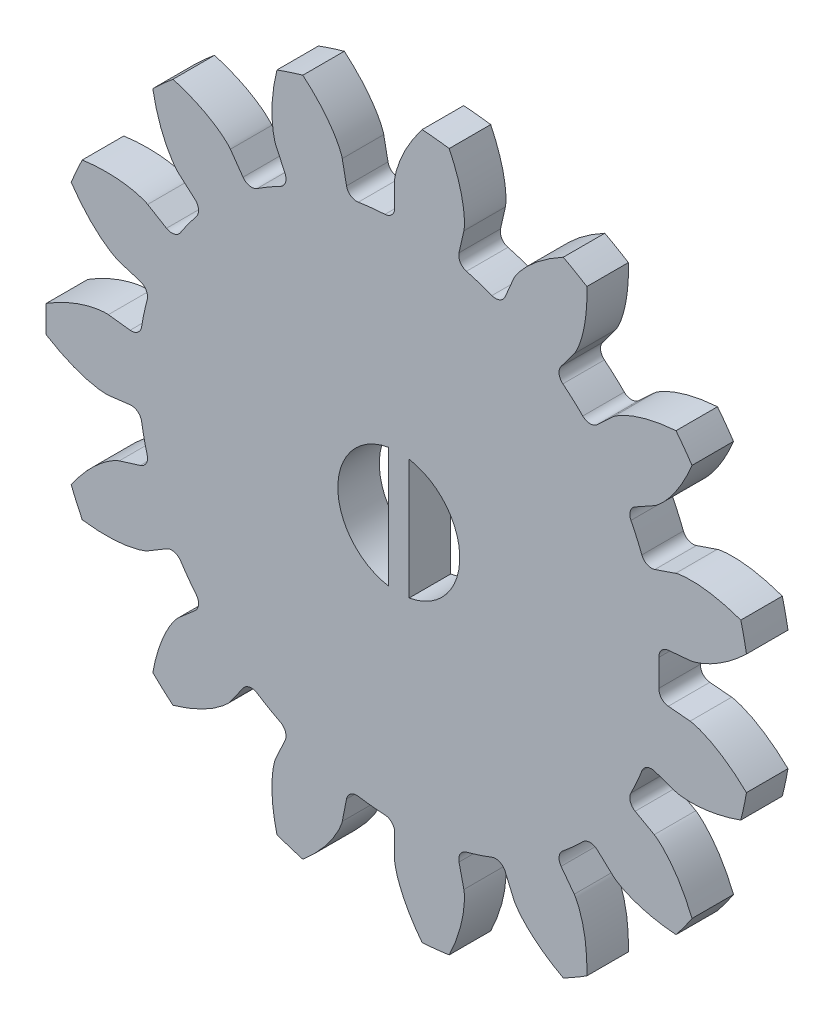
from build123d import *

# Parameters (mm, degrees)
BOSS_EXTRUDE1_DEPTH = 2


with BuildPart() as part:
    # Model → Boss-Extrude1 (new body)
    with BuildSketch(Plane.XY):
        with BuildLine():
            Line((-54.481196543, -102.831203323), (-54.924387915, -103.789903349))
            add(Edge.make_bspline(
                [(-54.924387915, -103.789903349), (-54.938844158, -103.821174719), (-54.95455115, -103.861076701), (-54.977503798, -103.934729714), (-54.997679447, -104.018619757), (-55.025551936, -104.136716214), (-55.044914627, -104.230522739), (-55.064352418, -104.351618793), (-55.078032946, -104.456434474), (-55.091533867, -104.579585969), (-55.103699645, -104.721366375), (-55.112590945, -104.900478214), (-55.116296533, -105.081064783), (-55.113044886, -105.299764415), (-55.100518203, -105.547871597), (-55.079947553, -105.78858276), (-55.051387133, -106.030757954), (-55.013189585, -106.283605293), (-54.970568466, -106.518677571), (-54.93325868, -106.697892255), (-54.903174984, -106.830156052), (-54.882766309, -106.915275478), (-54.873484818, -106.953124336)],
                knots=[0, 0, 0, 0, 0, 0, 0.057142857, 0.071428571, 0.128571429, 0.142857143, 0.2, 0.214285714, 0.271428571, 0.3, 0.342857143, 0.428571429, 0.5, 0.557142857, 0.642857143, 0.728571429, 0.8, 0.871428571, 0.942857143, 1, 1, 1, 1, 1, 1], degree=5))
            ThreePointArc((-54.873484818, -106.953124336), (-54.253288904, -107.167960777), (-53.625262179, -107.358696457))
            add(Edge.make_bspline(
                [(-51.724786063, -104.829517011), (-51.731471566, -104.863313247), (-51.74221814, -104.904826967), (-51.766941212, -104.977904734), (-51.799928099, -105.057632154), (-51.846794138, -105.169557232), (-51.886267484, -105.256829409), (-51.941720454, -105.366223422), (-51.992261787, -105.459062302), (-52.053725945, -105.566629597), (-52.127220056, -105.688483219), (-52.22530614, -105.838613916), (-52.328454378, -105.986889609), (-52.459633434, -106.161910058), (-52.615601476, -106.355269985), (-52.773729953, -106.537918282), (-52.939182826, -106.717054736), (-53.118705228, -106.899160575), (-53.291358456, -107.064285978), (-53.426882456, -107.18734356), (-53.528963386, -107.276664467), (-53.595506294, -107.333531611), (-53.625262179, -107.358696457)],
                knots=[0, 0, 0, 0, 0, 0, 0.057142857, 0.071428571, 0.128571429, 0.142857143, 0.2, 0.214285714, 0.271428571, 0.3, 0.342857143, 0.428571429, 0.5, 0.557142857, 0.642857143, 0.728571429, 0.8, 0.871428571, 0.942857143, 1, 1, 1, 1, 1, 1], degree=5))
            Line((-51.724786063, -104.829517011), (-51.519825677, -103.793411045))
            ThreePointArc((-51.519825677, -103.793411045), (-51.315631569, -103.480523025), (-50.951573701, -103.396522929))
            ThreePointArc((-50.951573701, -103.396522929), (-50.311748591, -103.480454169), (-49.668454909, -103.531384148))
            ThreePointArc((-49.668454909, -103.531384148), (-49.329817181, -103.689240527), (-49.195138281, -104.037745536))
            Line((-49.195138281, -104.037745536), (-49.210075315, -105.093823761))
            add(Edge.make_bspline(
                [(-49.210075315, -105.093823761), (-49.210562539, -105.128271463), (-49.208681991, -105.171112346), (-49.1996929, -105.247733405), (-49.184003118, -105.332576949), (-49.161431747, -105.451800193), (-49.140965894, -105.545372233), (-49.109468998, -105.663905045), (-49.079334403, -105.765223307), (-49.041577883, -105.883219116), (-48.995024587, -106.017690228), (-48.930295846, -106.184933453), (-48.860229895, -106.351414691), (-48.768306213, -106.549884183), (-48.655948236, -106.771446311), (-48.539249962, -106.982980063), (-48.414657195, -107.192601542), (-48.276919721, -107.408052738), (-48.142370881, -107.605466379), (-48.035393517, -107.754011882), (-47.95411416, -107.862604731), (-47.900848719, -107.932064241), (-47.876975137, -107.962865771)],
                knots=[0, 0, 0, 0, 0, 0, 0.057142857, 0.071428571, 0.128571429, 0.142857143, 0.2, 0.214285714, 0.271428571, 0.3, 0.342857143, 0.428571429, 0.5, 0.557142857, 0.642857143, 0.728571429, 0.8, 0.871428571, 0.942857143, 1, 1, 1, 1, 1, 1], degree=5))
            ThreePointArc((-47.876975137, -107.962865771), (-47.223016124, -107.906872221), (-46.571705972, -107.825676453))
            add(Edge.make_bspline(
                [(-45.864244606, -104.742162783), (-45.85660595, -104.77575642), (-45.849538282, -104.818052116), (-45.842400526, -104.894867757), (-45.840107485, -104.981119355), (-45.837397711, -105.102430137), (-45.837961614, -105.198212494), (-45.84412587, -105.320703653), (-45.852536701, -105.426073202), (-45.864935442, -105.549340541), (-45.88251332, -105.690552112), (-45.911055762, -105.867598533), (-45.944977208, -106.045009287), (-45.99362801, -106.258253752), (-46.057465338, -106.498334753), (-46.127633135, -106.729508921), (-46.205920495, -106.960453961), (-46.295853253, -107.199834261), (-46.386417273, -107.420908218), (-46.460172579, -107.58844949), (-46.517098063, -107.711568253), (-46.554758083, -107.790584414), (-46.571705972, -107.825676453)],
                knots=[0, 0, 0, 0, 0, 0, 0.057142857, 0.071428571, 0.128571429, 0.142857143, 0.2, 0.214285714, 0.271428571, 0.3, 0.342857143, 0.428571429, 0.5, 0.557142857, 0.642857143, 0.728571429, 0.8, 0.871428571, 0.942857143, 1, 1, 1, 1, 1, 1], degree=5))
            Line((-45.864244606, -104.742162783), (-46.098426239, -103.712267985))
            ThreePointArc((-46.098426239, -103.712267985), (-46.039148662, -103.343377329), (-45.740731168, -103.118563748))
            ThreePointArc((-45.740731168, -103.118563748), (-45.122083934, -102.934998434), (-44.513690824, -102.719874173))
            ThreePointArc((-44.513690824, -102.719874173), (-44.140123892, -102.726346778), (-43.875338838, -102.989943102))
            Line((-43.875338838, -102.989943102), (-43.459438785, -103.960794006))
            add(Edge.make_bspline(
                [(-43.459438785, -103.960794006), (-43.445872744, -103.992461719), (-43.426729821, -104.030833926), (-43.387353285, -104.097174553), (-43.338510978, -104.168301378), (-43.269398542, -104.268036627), (-43.212642878, -104.345194728), (-43.135657393, -104.440668898), (-43.066918222, -104.520970892), (-42.984432705, -104.613408467), (-42.887209824, -104.71731901), (-42.760053229, -104.843775747), (-42.628330778, -104.967365536), (-42.463629501, -105.111287709), (-42.270867945, -105.267994678), (-42.078220238, -105.413774913), (-41.879138345, -105.554597219), (-41.665677005, -105.695398802), (-41.462465163, -105.821019194), (-41.304317578, -105.913210649), (-41.1858965, -105.979355861), (-41.10898437, -106.021145273), (-41.074646657, -106.039573611)],
                knots=[0, 0, 0, 0, 0, 0, 0.057142857, 0.071428571, 0.128571429, 0.142857143, 0.2, 0.214285714, 0.271428571, 0.3, 0.342857143, 0.428571429, 0.5, 0.557142857, 0.642857143, 0.728571429, 0.8, 0.871428571, 0.942857143, 1, 1, 1, 1, 1, 1], degree=5))
            ThreePointArc((-41.074646657, -106.039573611), (-40.5, -105.722431864), (-39.938023863, -105.383344134))
            add(Edge.make_bspline(
                [(-40.545903745, -102.278663766), (-40.525261721, -102.306246159), (-40.501601877, -102.34201052), (-40.463837476, -102.409281914), (-40.426660993, -102.487144006), (-40.374843951, -102.596864755), (-40.336400908, -102.684595653), (-40.292210594, -102.799004123), (-40.257036613, -102.898684989), (-40.218226083, -103.016338329), (-40.176848354, -103.152491085), (-40.130911904, -103.325840295), (-40.089741233, -103.501710179), (-40.047451614, -103.716306755), (-40.008120175, -103.961596644), (-39.978194642, -104.201324569), (-39.955779894, -104.444145699), (-39.940572816, -104.699409434), (-39.933388287, -104.938206248), (-39.932621937, -105.121261802), (-39.934549042, -105.256890069), (-39.936814414, -105.344392634), (-39.938023863, -105.383344134)],
                knots=[0, 0, 0, 0, 0, 0, 0.057142857, 0.071428571, 0.128571429, 0.142857143, 0.2, 0.214285714, 0.271428571, 0.3, 0.342857143, 0.428571429, 0.5, 0.557142857, 0.642857143, 0.728571429, 0.8, 0.871428571, 0.942857143, 1, 1, 1, 1, 1, 1], degree=5))
            Line((-40.545903745, -102.278663766), (-41.178735265, -101.433058303))
            ThreePointArc((-41.178735265, -101.433058303), (-41.274623851, -101.071949557), (-41.093445825, -100.745194802))
            ThreePointArc((-41.093445825, -100.745194802), (-40.602946195, -100.325873044), (-40.134650353, -99.881891481))
            ThreePointArc((-40.134650353, -99.881891481), (-39.790747333, -99.73586114), (-39.441639865, -99.86897058))
            Line((-39.441639865, -99.86897058), (-38.666815624, -100.586725223))
            add(Edge.make_bspline(
                [(-38.666815624, -100.586725223), (-38.641542009, -100.610137312), (-38.608446696, -100.637405939), (-38.545491277, -100.681995238), (-38.471941722, -100.727106869), (-38.368238391, -100.790108993), (-38.285006484, -100.837511817), (-38.175843901, -100.893418994), (-38.08038578, -100.938819776), (-37.967433762, -100.98971582), (-37.836352015, -101.045098716), (-37.668754097, -101.108903448), (-37.498151153, -101.16823199), (-37.289150629, -101.232721393), (-37.049315719, -101.297477145), (-36.814029118, -101.352297135), (-36.574881167, -101.399970812), (-36.322605366, -101.44177691), (-36.085867694, -101.473883145), (-35.903895043, -101.493779813), (-35.768808324, -101.506040279), (-35.681548311, -101.512933825), (-35.64268377, -101.515802543)],
                knots=[0, 0, 0, 0, 0, 0, 0.057142857, 0.071428571, 0.128571429, 0.142857143, 0.2, 0.214285714, 0.271428571, 0.3, 0.342857143, 0.428571429, 0.5, 0.557142857, 0.642857143, 0.728571429, 0.8, 0.871428571, 0.942857143, 1, 1, 1, 1, 1, 1], degree=5))
            ThreePointArc((-35.64268377, -101.515802543), (-35.246711096, -100.992349289), (-34.871239753, -100.454000946))
            add(Edge.make_bspline(
                [(-36.689352929, -97.864981321), (-36.659276732, -97.881783223), (-36.623115713, -97.904832267), (-36.561254475, -97.950927578), (-36.495622702, -98.0069371), (-36.40365803, -98.086096103), (-36.332855192, -98.150606071), (-36.245951213, -98.237149589), (-36.173274322, -98.313906045), (-36.089965214, -98.405602055), (-35.996786462, -98.513153948), (-35.884313952, -98.652832294), (-35.775169946, -98.796751807), (-35.649252166, -98.975594797), (-35.513552722, -99.183680723), (-35.388708256, -99.390511269), (-35.269467114, -99.60322251), (-35.151749642, -99.83023226), (-35.048058833, -100.045461793), (-34.972903337, -100.21237966), (-34.919498849, -100.337066072), (-34.88597787, -100.417925053), (-34.871239753, -100.454000946)],
                knots=[0, 0, 0, 0, 0, 0, 0.057142857, 0.071428571, 0.128571429, 0.142857143, 0.2, 0.214285714, 0.271428571, 0.3, 0.342857143, 0.428571429, 0.5, 0.557142857, 0.642857143, 0.728571429, 0.8, 0.871428571, 0.942857143, 1, 1, 1, 1, 1, 1], degree=5))
            Line((-36.689352929, -97.864981321), (-37.611412017, -97.349878059))
            ThreePointArc((-37.611412017, -97.349878059), (-37.845886758, -97.058990206), (-37.813275528, -96.686793142))
            ThreePointArc((-37.813275528, -96.686793142), (-37.535735343, -96.104219481), (-37.288509374, -95.508149062))
            ThreePointArc((-37.288509374, -95.508149062), (-37.033734224, -95.234865748), (-36.660668195, -95.214472473))
            Line((-36.660668195, -95.214472473), (-35.660893915, -95.555024555))
            add(Edge.make_bspline(
                [(-35.660893915, -95.555024555), (-35.628282764, -95.566132858), (-35.586957542, -95.577582912), (-35.511308803, -95.592710987), (-35.425769388, -95.604007214), (-35.305406408, -95.619382573), (-35.210089813, -95.628833742), (-35.087625333, -95.635507067), (-34.981953838, -95.638156429), (-34.858065749, -95.638710554), (-34.715790362, -95.635989598), (-34.536730322, -95.626109906), (-34.356745686, -95.610918758), (-34.139584003, -95.584824587), (-33.894145373, -95.546432264), (-33.656903069, -95.500813134), (-33.419039913, -95.44709497), (-33.17157043, -95.382676929), (-32.942241022, -95.315717549), (-32.767908029, -95.259879114), (-32.63951339, -95.216134888), (-32.556993544, -95.186940612), (-32.520322206, -95.173753683)],
                knots=[0, 0, 0, 0, 0, 0, 0.057142857, 0.071428571, 0.128571429, 0.142857143, 0.2, 0.214285714, 0.271428571, 0.3, 0.342857143, 0.428571429, 0.5, 0.557142857, 0.642857143, 0.728571429, 0.8, 0.871428571, 0.942857143, 1, 1, 1, 1, 1, 1], degree=5))
            ThreePointArc((-32.520322206, -95.173753683), (-32.371490788, -94.534498744), (-32.247446646, -93.889975107))
            add(Edge.make_bspline(
                [(-34.96142483, -92.264281239), (-34.927114908, -92.267397449), (-34.884705282, -92.273745787), (-34.809443578, -92.290694716), (-34.726704844, -92.315167114), (-34.610494069, -92.350077059), (-34.51957389, -92.380211739), (-34.404982735, -92.423926145), (-34.307369428, -92.464486301), (-34.193966644, -92.514369908), (-34.065098322, -92.574724238), (-33.90553727, -92.656580066), (-33.747291919, -92.743664216), (-33.559518306, -92.855830042), (-33.350914525, -92.990732059), (-33.152737867, -93.128902345), (-32.957288207, -93.274723992), (-32.757414763, -93.434227708), (-32.575146757, -93.588674819), (-32.438597181, -93.710593384), (-32.339095222, -93.802778527), (-32.275583973, -93.863012671), (-32.247446646, -93.889975107)],
                knots=[0, 0, 0, 0, 0, 0, 0.057142857, 0.071428571, 0.128571429, 0.142857143, 0.2, 0.214285714, 0.271428571, 0.3, 0.342857143, 0.428571429, 0.5, 0.557142857, 0.642857143, 0.728571429, 0.8, 0.871428571, 0.942857143, 1, 1, 1, 1, 1, 1], degree=5))
            Line((-34.96142483, -92.264281239), (-36.013279093, -92.168746212))
            ThreePointArc((-36.013279093, -92.168746212), (-36.345797177, -91.998376404), (-36.467391521, -91.645093284))
            ThreePointArc((-36.467391521, -91.645093284), (-36.4508, -91), (-36.467391521, -90.354906716))
            ThreePointArc((-36.467391521, -90.354906716), (-36.345797177, -90.001623596), (-36.013279093, -89.831253788))
            Line((-36.013279093, -89.831253788), (-34.96142483, -89.735718761))
            add(Edge.make_bspline(
                [(-34.96142483, -89.735718761), (-34.927114908, -89.732602551), (-34.884705282, -89.726254213), (-34.809443578, -89.709305284), (-34.726704844, -89.684832886), (-34.610494069, -89.649922941), (-34.51957389, -89.619788261), (-34.404982735, -89.576073855), (-34.307369428, -89.535513699), (-34.193966644, -89.485630092), (-34.065098322, -89.425275762), (-33.90553727, -89.343419934), (-33.747291919, -89.256335784), (-33.559518306, -89.144169958), (-33.350914525, -89.009267941), (-33.152737867, -88.871097655), (-32.957288207, -88.725276008), (-32.757414763, -88.565772292), (-32.575146757, -88.411325181), (-32.438597181, -88.289406616), (-32.339095222, -88.197221473), (-32.275583973, -88.136987329), (-32.247446646, -88.110024893)],
                knots=[0, 0, 0, 0, 0, 0, 0.057142857, 0.071428571, 0.128571429, 0.142857143, 0.2, 0.214285714, 0.271428571, 0.3, 0.342857143, 0.428571429, 0.5, 0.557142857, 0.642857143, 0.728571429, 0.8, 0.871428571, 0.942857143, 1, 1, 1, 1, 1, 1], degree=5))
            ThreePointArc((-32.247446646, -88.110024893), (-32.371490788, -87.465501256), (-32.520322206, -86.826246317))
            add(Edge.make_bspline(
                [(-35.660893915, -86.444975445), (-35.628282764, -86.433867142), (-35.586957542, -86.422417088), (-35.511308803, -86.407289013), (-35.425769388, -86.395992786), (-35.305406408, -86.380617427), (-35.210089813, -86.371166258), (-35.087625333, -86.364492933), (-34.981953838, -86.361843571), (-34.858065749, -86.361289446), (-34.715790362, -86.364010402), (-34.536730322, -86.373890094), (-34.356745686, -86.389081242), (-34.139584003, -86.415175413), (-33.894145373, -86.453567736), (-33.656903069, -86.499186866), (-33.419039913, -86.55290503), (-33.17157043, -86.617323071), (-32.942241022, -86.684282451), (-32.767908029, -86.740120886), (-32.63951339, -86.783865112), (-32.556993544, -86.813059388), (-32.520322206, -86.826246317)],
                knots=[0, 0, 0, 0, 0, 0, 0.057142857, 0.071428571, 0.128571429, 0.142857143, 0.2, 0.214285714, 0.271428571, 0.3, 0.342857143, 0.428571429, 0.5, 0.557142857, 0.642857143, 0.728571429, 0.8, 0.871428571, 0.942857143, 1, 1, 1, 1, 1, 1], degree=5))
            Line((-35.660893915, -86.444975445), (-36.660668195, -86.785527527))
            ThreePointArc((-36.660668195, -86.785527527), (-37.033734224, -86.765134252), (-37.288509374, -86.491850938))
            ThreePointArc((-37.288509374, -86.491850938), (-37.535735343, -85.895780519), (-37.813275528, -85.313206858))
            ThreePointArc((-37.813275528, -85.313206858), (-37.845886758, -84.941009794), (-37.611412017, -84.650121941))
            Line((-37.611412017, -84.650121941), (-36.689352929, -84.135018679))
            add(Edge.make_bspline(
                [(-36.689352929, -84.135018679), (-36.659276732, -84.118216777), (-36.623115713, -84.095167733), (-36.561254475, -84.049072422), (-36.495622702, -83.9930629), (-36.40365803, -83.913903897), (-36.332855192, -83.849393929), (-36.245951213, -83.762850411), (-36.173274322, -83.686093955), (-36.089965214, -83.594397945), (-35.996786462, -83.486846052), (-35.884313952, -83.347167706), (-35.775169946, -83.203248193), (-35.649252166, -83.024405203), (-35.513552722, -82.816319277), (-35.388708256, -82.609488731), (-35.269467114, -82.39677749), (-35.151749642, -82.16976774), (-35.048058833, -81.954538207), (-34.972903337, -81.78762034), (-34.919498849, -81.662933928), (-34.88597787, -81.582074947), (-34.871239753, -81.545999054)],
                knots=[0, 0, 0, 0, 0, 0, 0.057142857, 0.071428571, 0.128571429, 0.142857143, 0.2, 0.214285714, 0.271428571, 0.3, 0.342857143, 0.428571429, 0.5, 0.557142857, 0.642857143, 0.728571429, 0.8, 0.871428571, 0.942857143, 1, 1, 1, 1, 1, 1], degree=5))
            ThreePointArc((-34.871239753, -81.545999054), (-35.246711096, -81.007650711), (-35.64268377, -80.484197457))
            add(Edge.make_bspline(
                [(-38.666815624, -81.413274777), (-38.641542009, -81.389862688), (-38.608446696, -81.362594061), (-38.545491277, -81.318004762), (-38.471941722, -81.272893131), (-38.368238391, -81.209891007), (-38.285006484, -81.162488183), (-38.175843901, -81.106581006), (-38.08038578, -81.061180224), (-37.967433762, -81.01028418), (-37.836352015, -80.954901284), (-37.668754097, -80.891096552), (-37.498151153, -80.83176801), (-37.289150629, -80.767278607), (-37.049315719, -80.702522855), (-36.814029118, -80.647702865), (-36.574881167, -80.600029188), (-36.322605366, -80.55822309), (-36.085867694, -80.526116855), (-35.903895043, -80.506220187), (-35.768808324, -80.493959721), (-35.681548311, -80.487066175), (-35.64268377, -80.484197457)],
                knots=[0, 0, 0, 0, 0, 0, 0.057142857, 0.071428571, 0.128571429, 0.142857143, 0.2, 0.214285714, 0.271428571, 0.3, 0.342857143, 0.428571429, 0.5, 0.557142857, 0.642857143, 0.728571429, 0.8, 0.871428571, 0.942857143, 1, 1, 1, 1, 1, 1], degree=5))
            Line((-38.666815624, -81.413274777), (-39.441639865, -82.13102942))
            ThreePointArc((-39.441639865, -82.13102942), (-39.790747333, -82.26413886), (-40.134650353, -82.118108519))
            ThreePointArc((-40.134650353, -82.118108519), (-40.602946195, -81.674126956), (-41.093445825, -81.254805198))
            ThreePointArc((-41.093445825, -81.254805198), (-41.274623851, -80.928050443), (-41.178735265, -80.566941697))
            Line((-41.178735265, -80.566941697), (-40.545903745, -79.721336234))
            add(Edge.make_bspline(
                [(-40.545903745, -79.721336234), (-40.525261721, -79.693753841), (-40.501601877, -79.65798948), (-40.463837476, -79.590718086), (-40.426660993, -79.512855994), (-40.374843951, -79.403135245), (-40.336400908, -79.315404347), (-40.292210594, -79.200995877), (-40.257036613, -79.101315011), (-40.218226083, -78.983661671), (-40.176848354, -78.847508915), (-40.130911904, -78.674159705), (-40.089741233, -78.498289821), (-40.047451614, -78.283693245), (-40.008120175, -78.038403356), (-39.978194642, -77.798675431), (-39.955779894, -77.555854301), (-39.940572816, -77.300590566), (-39.933388287, -77.061793752), (-39.932621937, -76.878738198), (-39.934549042, -76.743109931), (-39.936814414, -76.655607366), (-39.938023863, -76.616655866)],
                knots=[0, 0, 0, 0, 0, 0, 0.057142857, 0.071428571, 0.128571429, 0.142857143, 0.2, 0.214285714, 0.271428571, 0.3, 0.342857143, 0.428571429, 0.5, 0.557142857, 0.642857143, 0.728571429, 0.8, 0.871428571, 0.942857143, 1, 1, 1, 1, 1, 1], degree=5))
            ThreePointArc((-39.938023863, -76.616655866), (-40.5, -76.277568136), (-41.074646657, -75.960426389))
            add(Edge.make_bspline(
                [(-43.459438785, -78.039205994), (-43.445872744, -78.007538281), (-43.426729821, -77.969166074), (-43.387353285, -77.902825447), (-43.338510978, -77.831698622), (-43.269398542, -77.731963373), (-43.212642878, -77.654805272), (-43.135657393, -77.559331102), (-43.066918222, -77.479029108), (-42.984432705, -77.386591533), (-42.887209824, -77.28268099), (-42.760053229, -77.156224253), (-42.628330778, -77.032634464), (-42.463629501, -76.888712291), (-42.270867945, -76.732005322), (-42.078220238, -76.586225087), (-41.879138345, -76.445402781), (-41.665677005, -76.304601198), (-41.462465163, -76.178980806), (-41.304317578, -76.086789351), (-41.1858965, -76.020644139), (-41.10898437, -75.978854727), (-41.074646657, -75.960426389)],
                knots=[0, 0, 0, 0, 0, 0, 0.057142857, 0.071428571, 0.128571429, 0.142857143, 0.2, 0.214285714, 0.271428571, 0.3, 0.342857143, 0.428571429, 0.5, 0.557142857, 0.642857143, 0.728571429, 0.8, 0.871428571, 0.942857143, 1, 1, 1, 1, 1, 1], degree=5))
            Line((-43.459438785, -78.039205994), (-43.875338838, -79.010056898))
            ThreePointArc((-43.875338838, -79.010056898), (-44.140123892, -79.273653222), (-44.513690824, -79.280125827))
            ThreePointArc((-44.513690824, -79.280125827), (-45.122083934, -79.065001566), (-45.740731168, -78.881436252))
            ThreePointArc((-45.740731168, -78.881436252), (-46.039148662, -78.656622671), (-46.098426239, -78.287732015))
            Line((-46.098426239, -78.287732015), (-45.864244606, -77.257837217))
            add(Edge.make_bspline(
                [(-45.864244606, -77.257837217), (-45.85660595, -77.22424358), (-45.849538282, -77.181947884), (-45.842400526, -77.105132243), (-45.840107485, -77.018880645), (-45.837397711, -76.897569863), (-45.837961614, -76.801787506), (-45.84412587, -76.679296347), (-45.852536701, -76.573926798), (-45.864935442, -76.450659459), (-45.88251332, -76.309447888), (-45.911055762, -76.132401467), (-45.944977208, -75.954990713), (-45.99362801, -75.741746248), (-46.057465338, -75.501665247), (-46.127633135, -75.270491079), (-46.205920495, -75.039546039), (-46.295853253, -74.800165739), (-46.386417273, -74.579091782), (-46.460172579, -74.41155051), (-46.517098063, -74.288431747), (-46.554758083, -74.209415586), (-46.571705972, -74.174323547)],
                knots=[0, 0, 0, 0, 0, 0, 0.057142857, 0.071428571, 0.128571429, 0.142857143, 0.2, 0.214285714, 0.271428571, 0.3, 0.342857143, 0.428571429, 0.5, 0.557142857, 0.642857143, 0.728571429, 0.8, 0.871428571, 0.942857143, 1, 1, 1, 1, 1, 1], degree=5))
            ThreePointArc((-46.571705972, -74.174323547), (-47.223016124, -74.093127779), (-47.876975137, -74.037134229))
            add(Edge.make_bspline(
                [(-49.210075315, -76.906176239), (-49.210562539, -76.871728537), (-49.208681991, -76.828887654), (-49.1996929, -76.752266595), (-49.184003118, -76.667423051), (-49.161431747, -76.548199807), (-49.140965894, -76.454627767), (-49.109468998, -76.336094955), (-49.079334403, -76.234776693), (-49.041577883, -76.116780884), (-48.995024587, -75.982309772), (-48.930295846, -75.815066547), (-48.860229895, -75.648585309), (-48.768306213, -75.450115817), (-48.655948236, -75.228553689), (-48.539249962, -75.017019937), (-48.414657195, -74.807398458), (-48.276919721, -74.591947262), (-48.142370881, -74.394533621), (-48.035393517, -74.245988118), (-47.95411416, -74.137395269), (-47.900848719, -74.067935759), (-47.876975137, -74.037134229)],
                knots=[0, 0, 0, 0, 0, 0, 0.057142857, 0.071428571, 0.128571429, 0.142857143, 0.2, 0.214285714, 0.271428571, 0.3, 0.342857143, 0.428571429, 0.5, 0.557142857, 0.642857143, 0.728571429, 0.8, 0.871428571, 0.942857143, 1, 1, 1, 1, 1, 1], degree=5))
            Line((-49.210075315, -76.906176239), (-49.195138281, -77.962254464))
            ThreePointArc((-49.195138281, -77.962254464), (-49.329817181, -78.310759473), (-49.668454909, -78.468615852))
            ThreePointArc((-49.668454909, -78.468615852), (-50.311748591, -78.519545831), (-50.951573701, -78.603477071))
            ThreePointArc((-50.951573701, -78.603477071), (-51.315631569, -78.519476975), (-51.519825677, -78.206588955))
            Line((-51.519825677, -78.206588955), (-51.724786063, -77.170482989))
            add(Edge.make_bspline(
                [(-51.724786063, -77.170482989), (-51.731471566, -77.136686753), (-51.74221814, -77.095173033), (-51.766941212, -77.022095266), (-51.799928099, -76.942367846), (-51.846794138, -76.830442768), (-51.886267484, -76.743170591), (-51.941720454, -76.633776578), (-51.992261787, -76.540937698), (-52.053725945, -76.433370403), (-52.127220056, -76.311516781), (-52.22530614, -76.161386084), (-52.328454378, -76.013110391), (-52.459633434, -75.838089942), (-52.615601476, -75.644730015), (-52.773729953, -75.462081718), (-52.939182826, -75.282945264), (-53.118705228, -75.100839425), (-53.291358456, -74.935714022), (-53.426882456, -74.81265644), (-53.528963386, -74.723335533), (-53.595506294, -74.666468389), (-53.625262179, -74.641303543)],
                knots=[0, 0, 0, 0, 0, 0, 0.057142857, 0.071428571, 0.128571429, 0.142857143, 0.2, 0.214285714, 0.271428571, 0.3, 0.342857143, 0.428571429, 0.5, 0.557142857, 0.642857143, 0.728571429, 0.8, 0.871428571, 0.942857143, 1, 1, 1, 1, 1, 1], degree=5))
            ThreePointArc((-53.625262179, -74.641303543), (-54.253288904, -74.832039223), (-54.873484818, -75.046875664))
            add(Edge.make_bspline(
                [(-54.924387915, -78.210096651), (-54.938844158, -78.178825281), (-54.95455115, -78.138923299), (-54.977503798, -78.065270286), (-54.997679447, -77.981380243), (-55.025551936, -77.863283786), (-55.044914627, -77.769477261), (-55.064352418, -77.648381207), (-55.078032946, -77.543565526), (-55.091533867, -77.420414031), (-55.103699645, -77.278633625), (-55.112590945, -77.099521786), (-55.116296533, -76.918935217), (-55.113044886, -76.700235585), (-55.100518203, -76.452128403), (-55.079947553, -76.21141724), (-55.051387133, -75.969242046), (-55.013189585, -75.716394707), (-54.970568466, -75.481322429), (-54.93325868, -75.302107745), (-54.903174984, -75.169843948), (-54.882766309, -75.084724522), (-54.873484818, -75.046875664)],
                knots=[0, 0, 0, 0, 0, 0, 0.057142857, 0.071428571, 0.128571429, 0.142857143, 0.2, 0.214285714, 0.271428571, 0.3, 0.342857143, 0.428571429, 0.5, 0.557142857, 0.642857143, 0.728571429, 0.8, 0.871428571, 0.942857143, 1, 1, 1, 1, 1, 1], degree=5))
            Line((-54.924387915, -78.210096651), (-54.481196543, -79.168796677))
            ThreePointArc((-54.481196543, -79.168796677), (-54.462482083, -79.541950688), (-54.707637068, -79.823896039))
            ThreePointArc((-54.707637068, -79.823896039), (-55.2746, -80.132074003), (-55.824971412, -80.468989323))
            ThreePointArc((-55.824971412, -80.468989323), (-56.19172074, -80.540327093), (-56.505524364, -80.337542889))
            Line((-56.505524364, -80.337542889), (-57.114187255, -79.474377889))
            add(Edge.make_bspline(
                [(-57.114187255, -79.474377889), (-57.134040934, -79.44622273), (-57.160743568, -79.412669086), (-57.213052624, -79.355965003), (-57.275615709, -79.296547356), (-57.363953996, -79.213360845), (-57.435511484, -79.149689), (-57.530664847, -79.072307352), (-57.614597626, -79.008051827), (-57.714499489, -78.934783938), (-57.831202033, -78.853357863), (-57.981871786, -78.756101852), (-58.136411547, -78.662599434), (-58.327436809, -78.556065627), (-58.548567273, -78.442860462), (-58.76731458, -78.340319585), (-58.99132466, -78.243966038), (-59.229395652, -78.150622415), (-59.454284777, -78.069997248), (-59.628144139, -78.012701129), (-59.757729795, -77.972622475), (-59.841649718, -77.947737193), (-59.879068536, -77.936850771)],
                knots=[0, 0, 0, 0, 0, 0, 0.057142857, 0.071428571, 0.128571429, 0.142857143, 0.2, 0.214285714, 0.271428571, 0.3, 0.342857143, 0.428571429, 0.5, 0.557142857, 0.642857143, 0.728571429, 0.8, 0.871428571, 0.942857143, 1, 1, 1, 1, 1, 1], degree=5))
            ThreePointArc((-59.879068536, -77.936850771), (-60.375220308, -78.366537967), (-60.854415615, -78.815057225))
            add(Edge.make_bspline(
                [(-59.614320022, -81.725507544), (-59.64024567, -81.702819611), (-59.670824319, -81.672755945), (-59.721749986, -81.614806253), (-59.774302513, -81.54637506), (-59.847799454, -81.449825341), (-59.903642704, -81.372004333), (-59.970654213, -81.269283645), (-60.025784375, -81.179094127), (-60.088208306, -81.072080957), (-60.156989583, -80.947506379), (-60.237963538, -80.78749599), (-60.314799936, -80.624029149), (-60.400782563, -80.422914529), (-60.490253151, -80.191162279), (-60.569366977, -79.962894852), (-60.641777261, -79.730040235), (-60.709724342, -79.483516355), (-60.766400522, -79.251431571), (-60.805209515, -79.072535554), (-60.831523224, -78.939470422), (-60.847500162, -78.853409), (-60.854415615, -78.815057225)],
                knots=[0, 0, 0, 0, 0, 0, 0.057142857, 0.071428571, 0.128571429, 0.142857143, 0.2, 0.214285714, 0.271428571, 0.3, 0.342857143, 0.428571429, 0.5, 0.557142857, 0.642857143, 0.728571429, 0.8, 0.871428571, 0.942857143, 1, 1, 1, 1, 1, 1], degree=5))
            Line((-59.614320022, -81.725507544), (-58.819506128, -82.421061428))
            ThreePointArc((-58.819506128, -82.421061428), (-58.650634207, -82.754342723), (-58.759916925, -83.111626133))
            ThreePointArc((-58.759916925, -83.111626133), (-59.152516066, -83.623765312), (-59.518269563, -84.155408993))
            ThreePointArc((-59.518269563, -84.155408993), (-59.824296061, -84.369749679), (-60.193449702, -84.312132523))
            Line((-60.193449702, -84.312132523), (-61.100571756, -83.77115756))
            add(Edge.make_bspline(
                [(-61.100571756, -83.77115756), (-61.130160729, -83.753511761), (-61.168202296, -83.733719921), (-61.239052625, -83.703194173), (-61.32037418, -83.674360151), (-61.434910224, -83.63429591), (-61.526178914, -83.605233838), (-61.644579789, -83.573244544), (-61.747391275, -83.548682738), (-61.868456903, -83.522382939), (-62.00818895, -83.49546372), (-62.185390202, -83.467898842), (-62.364600159, -83.445337116), (-62.582441622, -83.425710614), (-62.830499041, -83.412234412), (-63.072041782, -83.407531206), (-63.315875692, -83.410620968), (-63.571330637, -83.422179522), (-63.809570285, -83.439995414), (-63.991703147, -83.458367778), (-64.126386991, -83.474461341), (-64.213173412, -83.485860812), (-64.25178511, -83.491135175)],
                knots=[0, 0, 0, 0, 0, 0, 0.057142857, 0.071428571, 0.128571429, 0.142857143, 0.2, 0.214285714, 0.271428571, 0.3, 0.342857143, 0.428571429, 0.5, 0.557142857, 0.642857143, 0.728571429, 0.8, 0.871428571, 0.942857143, 1, 1, 1, 1, 1, 1], degree=5))
            ThreePointArc((-64.25178511, -83.491135175), (-64.53027278, -84.085477068), (-64.785610259, -84.69012609))
            add(Edge.make_bspline(
                [(-62.46893977, -86.844562439), (-62.501852041, -86.834380892), (-62.542015022, -86.819353824), (-62.612108197, -86.78712748), (-62.687950793, -86.745987514), (-62.794363898, -86.687678856), (-62.877031901, -86.639299323), (-62.980030228, -86.572715341), (-63.06707752, -86.512746574), (-63.167630796, -86.440375279), (-63.281134664, -86.354546604), (-63.420190142, -86.241304915), (-63.556871638, -86.123222704), (-63.717221362, -85.974467641), (-63.893218943, -85.799142392), (-64.058337747, -85.622788214), (-64.219198338, -85.439516851), (-64.381541381, -85.241942648), (-64.527715033, -85.052974928), (-64.635932378, -84.905330323), (-64.714093613, -84.794472026), (-64.763693605, -84.722349411), (-64.785610259, -84.69012609)],
                knots=[0, 0, 0, 0, 0, 0, 0.057142857, 0.071428571, 0.128571429, 0.142857143, 0.2, 0.214285714, 0.271428571, 0.3, 0.342857143, 0.428571429, 0.5, 0.557142857, 0.642857143, 0.728571429, 0.8, 0.871428571, 0.942857143, 1, 1, 1, 1, 1, 1], degree=5))
            Line((-62.46893977, -86.844562439), (-61.459933895, -87.156702595))
            ThreePointArc((-61.459933895, -87.156702595), (-61.170104004, -87.392483811), (-61.124618479, -87.763327732))
            ThreePointArc((-61.124618479, -87.763327732), (-61.274969871, -88.39087461), (-61.39286335, -89.025320629))
            ThreePointArc((-61.39286335, -89.025320629), (-61.585252257, -89.34560278), (-61.945925897, -89.443115201))
            Line((-61.945925897, -89.443115201), (-62.99465747, -89.31786976))
            add(Edge.make_bspline(
                [(-62.99465747, -89.31786976), (-63.028865535, -89.31378444), (-63.071668302, -89.311176594), (-63.148809238, -89.312107361), (-63.234828029, -89.318842628), (-63.355757507, -89.328828128), (-63.450956214, -89.339400925), (-63.572132013, -89.358335225), (-63.676045166, -89.377714097), (-63.797341212, -89.402929862), (-63.935941822, -89.435172076), (-64.109034867, -89.482064549), (-64.281927989, -89.534344643), (-64.488918885, -89.605019047), (-64.72101188, -89.693601966), (-64.94358512, -89.787549657), (-65.165081761, -89.889548481), (-65.393750178, -90.004010632), (-65.60414655, -90.117187054), (-65.763060485, -90.208051152), (-65.879554458, -90.277534208), (-65.954201216, -90.323247361), (-65.98732948, -90.343770524)],
                knots=[0, 0, 0, 0, 0, 0, 0.057142857, 0.071428571, 0.128571429, 0.142857143, 0.2, 0.214285714, 0.271428571, 0.3, 0.342857143, 0.428571429, 0.5, 0.557142857, 0.642857143, 0.728571429, 0.8, 0.871428571, 0.942857143, 1, 1, 1, 1, 1, 1], degree=5))
            ThreePointArc((-65.98732948, -90.343770524), (-66, -91), (-65.98732948, -91.656229476))
            add(Edge.make_bspline(
                [(-62.99465747, -92.68213024), (-63.028865535, -92.68621556), (-63.071668302, -92.688823406), (-63.148809238, -92.687892639), (-63.234828029, -92.681157372), (-63.355757507, -92.671171872), (-63.450956214, -92.660599075), (-63.572132013, -92.641664775), (-63.676045166, -92.622285903), (-63.797341212, -92.597070138), (-63.935941822, -92.564827924), (-64.109034867, -92.517935451), (-64.281927989, -92.465655357), (-64.488918885, -92.394980953), (-64.72101188, -92.306398034), (-64.94358512, -92.212450343), (-65.165081761, -92.110451519), (-65.393750178, -91.995989368), (-65.60414655, -91.882812946), (-65.763060485, -91.791948848), (-65.879554458, -91.722465792), (-65.954201216, -91.676752639), (-65.98732948, -91.656229476)],
                knots=[0, 0, 0, 0, 0, 0, 0.057142857, 0.071428571, 0.128571429, 0.142857143, 0.2, 0.214285714, 0.271428571, 0.3, 0.342857143, 0.428571429, 0.5, 0.557142857, 0.642857143, 0.728571429, 0.8, 0.871428571, 0.942857143, 1, 1, 1, 1, 1, 1], degree=5))
            Line((-62.99465747, -92.68213024), (-61.945925897, -92.556884799))
            ThreePointArc((-61.945925897, -92.556884799), (-61.585252257, -92.65439722), (-61.39286335, -92.974679371))
            ThreePointArc((-61.39286335, -92.974679371), (-61.274969871, -93.60912539), (-61.124618479, -94.236672268))
            ThreePointArc((-61.124618479, -94.236672268), (-61.170104004, -94.607516189), (-61.459933895, -94.843297405))
            Line((-61.459933895, -94.843297405), (-62.46893977, -95.155437561))
            add(Edge.make_bspline(
                [(-62.46893977, -95.155437561), (-62.501852041, -95.165619108), (-62.542015022, -95.180646176), (-62.612108197, -95.21287252), (-62.687950793, -95.254012486), (-62.794363898, -95.312321144), (-62.877031901, -95.360700677), (-62.980030228, -95.427284659), (-63.06707752, -95.487253426), (-63.167630796, -95.559624721), (-63.281134664, -95.645453396), (-63.420190142, -95.758695085), (-63.556871638, -95.876777296), (-63.717221362, -96.025532359), (-63.893218943, -96.200857608), (-64.058337747, -96.377211786), (-64.219198338, -96.560483149), (-64.381541381, -96.758057352), (-64.527715033, -96.947025072), (-64.635932378, -97.094669677), (-64.714093613, -97.205527974), (-64.763693605, -97.277650589), (-64.785610259, -97.30987391)],
                knots=[0, 0, 0, 0, 0, 0, 0.057142857, 0.071428571, 0.128571429, 0.142857143, 0.2, 0.214285714, 0.271428571, 0.3, 0.342857143, 0.428571429, 0.5, 0.557142857, 0.642857143, 0.728571429, 0.8, 0.871428571, 0.942857143, 1, 1, 1, 1, 1, 1], degree=5))
            ThreePointArc((-64.785610259, -97.30987391), (-64.53027278, -97.914522932), (-64.25178511, -98.508864825))
            add(Edge.make_bspline(
                [(-61.100571756, -98.22884244), (-61.130160729, -98.246488239), (-61.168202296, -98.266280079), (-61.239052625, -98.296805827), (-61.32037418, -98.325639849), (-61.434910224, -98.36570409), (-61.526178914, -98.394766162), (-61.644579789, -98.426755456), (-61.747391275, -98.451317262), (-61.868456903, -98.477617061), (-62.00818895, -98.50453628), (-62.185390202, -98.532101158), (-62.364600159, -98.554662884), (-62.582441622, -98.574289386), (-62.830499041, -98.587765588), (-63.072041782, -98.592468794), (-63.315875692, -98.589379032), (-63.571330637, -98.577820478), (-63.809570285, -98.560004586), (-63.991703147, -98.541632222), (-64.126386991, -98.525538659), (-64.213173412, -98.514139188), (-64.25178511, -98.508864825)],
                knots=[0, 0, 0, 0, 0, 0, 0.057142857, 0.071428571, 0.128571429, 0.142857143, 0.2, 0.214285714, 0.271428571, 0.3, 0.342857143, 0.428571429, 0.5, 0.557142857, 0.642857143, 0.728571429, 0.8, 0.871428571, 0.942857143, 1, 1, 1, 1, 1, 1], degree=5))
            Line((-61.100571756, -98.22884244), (-60.193449702, -97.687867477))
            ThreePointArc((-60.193449702, -97.687867477), (-59.824296061, -97.630250321), (-59.518269563, -97.844591007))
            ThreePointArc((-59.518269563, -97.844591007), (-59.152516066, -98.376234688), (-58.759916925, -98.888373867))
            ThreePointArc((-58.759916925, -98.888373867), (-58.650634207, -99.245657277), (-58.819506128, -99.578938572))
            Line((-58.819506128, -99.578938572), (-59.614320022, -100.274492456))
            add(Edge.make_bspline(
                [(-59.614320022, -100.274492456), (-59.64024567, -100.297180389), (-59.670824319, -100.327244055), (-59.721749986, -100.385193747), (-59.774302513, -100.45362494), (-59.847799454, -100.550174659), (-59.903642704, -100.627995667), (-59.970654213, -100.730716355), (-60.025784375, -100.820905873), (-60.088208306, -100.927919043), (-60.156989583, -101.052493621), (-60.237963538, -101.21250401), (-60.314799936, -101.375970851), (-60.400782563, -101.577085471), (-60.490253151, -101.808837721), (-60.569366977, -102.037105148), (-60.641777261, -102.269959765), (-60.709724342, -102.516483645), (-60.766400522, -102.748568429), (-60.805209515, -102.927464446), (-60.831523224, -103.060529578), (-60.847500162, -103.146591), (-60.854415615, -103.184942775)],
                knots=[0, 0, 0, 0, 0, 0, 0.057142857, 0.071428571, 0.128571429, 0.142857143, 0.2, 0.214285714, 0.271428571, 0.3, 0.342857143, 0.428571429, 0.5, 0.557142857, 0.642857143, 0.728571429, 0.8, 0.871428571, 0.942857143, 1, 1, 1, 1, 1, 1], degree=5))
            ThreePointArc((-60.854415615, -103.184942775), (-60.375220308, -103.633462033), (-59.879068536, -104.063149229))
            add(Edge.make_bspline(
                [(-57.114187255, -102.525622111), (-57.134040934, -102.55377727), (-57.160743568, -102.587330914), (-57.213052624, -102.644034997), (-57.275615709, -102.703452644), (-57.363953996, -102.786639155), (-57.435511484, -102.850311), (-57.530664847, -102.927692648), (-57.614597626, -102.991948173), (-57.714499489, -103.065216062), (-57.831202033, -103.146642137), (-57.981871786, -103.243898148), (-58.136411547, -103.337400566), (-58.327436809, -103.443934373), (-58.548567273, -103.557139538), (-58.76731458, -103.659680415), (-58.99132466, -103.756033962), (-59.229395652, -103.849377585), (-59.454284777, -103.930002752), (-59.628144139, -103.987298871), (-59.757729795, -104.027377525), (-59.841649718, -104.052262807), (-59.879068536, -104.063149229)],
                knots=[0, 0, 0, 0, 0, 0, 0.057142857, 0.071428571, 0.128571429, 0.142857143, 0.2, 0.214285714, 0.271428571, 0.3, 0.342857143, 0.428571429, 0.5, 0.557142857, 0.642857143, 0.728571429, 0.8, 0.871428571, 0.942857143, 1, 1, 1, 1, 1, 1], degree=5))
            Line((-57.114187255, -102.525622111), (-56.505524364, -101.662457111))
            ThreePointArc((-56.505524364, -101.662457111), (-56.19172074, -101.459672907), (-55.824971412, -101.531010677))
            ThreePointArc((-55.824971412, -101.531010677), (-55.2746, -101.867925997), (-54.707637068, -102.176103961))
            ThreePointArc((-54.707637068, -102.176103961), (-54.462482083, -102.458049312), (-54.481196543, -102.831203323))
        make_face()
        with BuildLine():
            Line((-48.5, -93.894634044), (-48.5, -88.105365956))
            ThreePointArc((-48.5, -88.105365956), (-46.0625, -91), (-48.5, -93.894634044))
        make_face(mode=Mode.SUBTRACT)
        with BuildLine():
            Line((-49.5, -88.105365956), (-49.5, -93.894634044))
            ThreePointArc((-49.5, -93.894634044), (-51.9375, -91), (-49.5, -88.105365956))
        make_face(mode=Mode.SUBTRACT)
    extrude(amount=BOSS_EXTRUDE1_DEPTH)


solid = part.part
